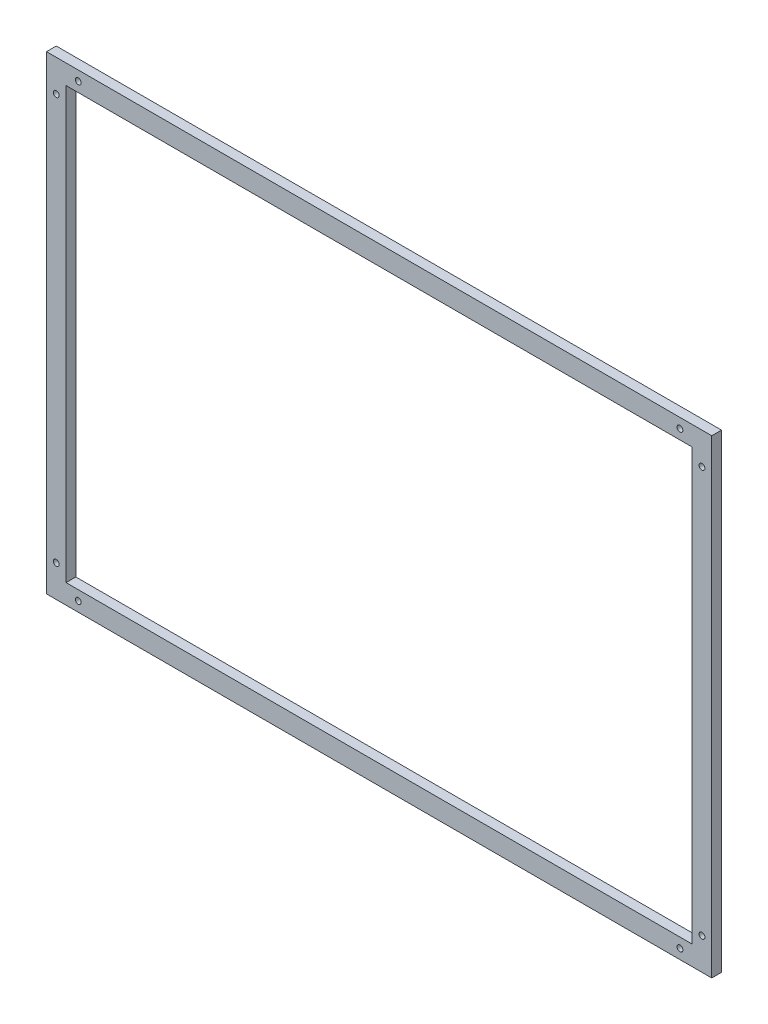
from build123d import *

# Parameters (mm, degrees)
ESQUISSE1_W             = 680
ESQUISSE1_H             = 480
ESQUISSE1_W_2           = 640
ESQUISSE1_H_2           = 440
BOSS_EXTRU_1_DEPTH      = 10
ESQUISSE2_R             = 3
ENL_V_MAT_EXTRU_1_DEPTH = 11


with BuildPart() as part:
    # Esquisse1 → Boss.-Extru.1 (new body)
    with BuildSketch(Plane.XY):
        with Locations((-340, 240)):
            Rectangle(ESQUISSE1_W, ESQUISSE1_H)
        with Locations((-340, 240)):
            Rectangle(ESQUISSE1_W_2, ESQUISSE1_H_2, mode=Mode.SUBTRACT)
    extrude(amount=BOSS_EXTRU_1_DEPTH)

    # Esquisse2 → Enlèv. mat.-Extru.1 (cut, through all)
    with BuildSketch(Plane.XY.offset(10)):
        with Locations((-32.5, 470)):
            Circle(ESQUISSE2_R)
        with Locations((-10, 447.5)):
            Circle(ESQUISSE2_R)
        with Locations((-647.5, 470)):
            Circle(ESQUISSE2_R)
        with Locations((-670, 447.5)):
            Circle(ESQUISSE2_R)
        with Locations((-670, 32.5)):
            Circle(ESQUISSE2_R)
        with Locations((-647.5, 10)):
            Circle(ESQUISSE2_R)
        with Locations((-32.5, 10)):
            Circle(ESQUISSE2_R)
        with Locations((-10, 32.5)):
            Circle(ESQUISSE2_R)
    extrude(amount=-ENL_V_MAT_EXTRU_1_DEPTH, mode=Mode.SUBTRACT)


solid = part.part
